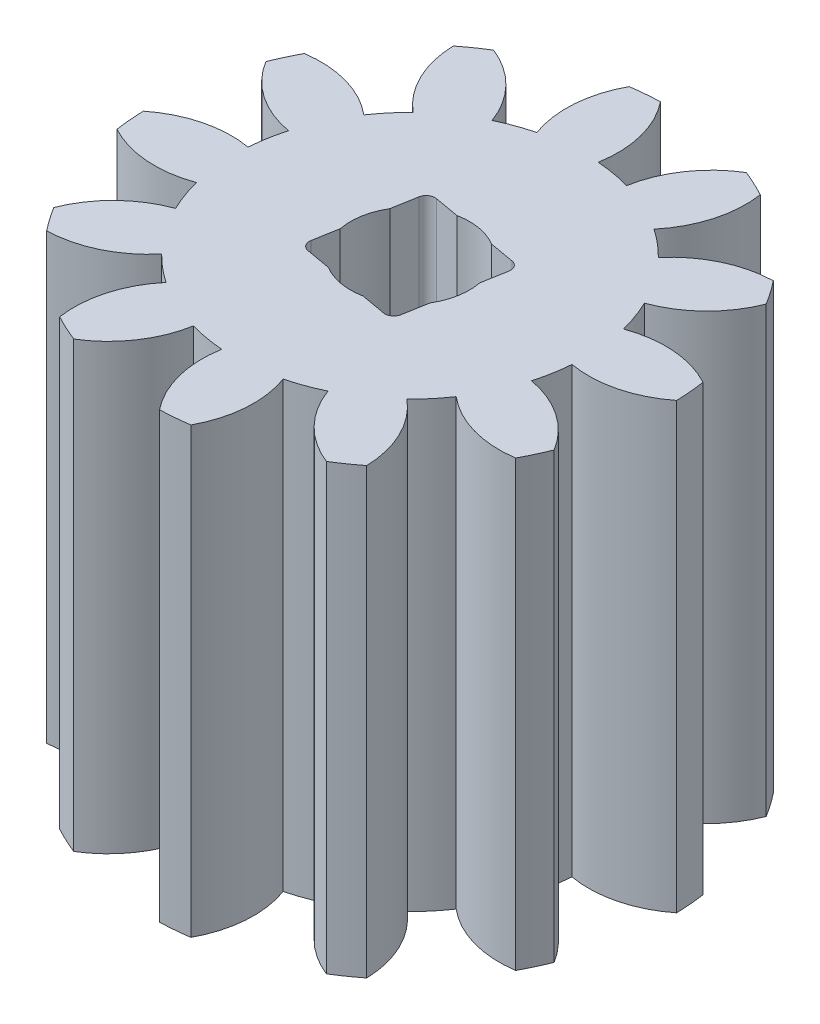
from build123d import *

# Parameters (mm, degrees)
BOSS_EXTRUDE1_DEPTH = 12.7
SKETCH2_R           = 1.7018
CUT_EXTRUDE1_DEPTH  = 56.896


with BuildPart() as part:
    # Sketch1 → Boss-Extrude1 (new body)
    with BuildSketch(Plane.XZ.offset(6.35)):
        with BuildLine():
            ThreePointArc((3.900741532, 6.293125734), (2.850773823, 5.595435975), (2.180140266, 4.527983952))
            ThreePointArc((2.180140266, 4.527983952), (1.71882223, 4.722425266), (1.240447645, 4.870004095))
            ThreePointArc((1.240447645, 4.870004095), (1.41285747, 6.118794727), (1.057001873, 7.328162323))
            ThreePointArc((1.057001873, 7.328162323), (0.645301119, 7.375825545), (0.231578393, 7.400377521))
            ThreePointArc((0.231578393, 7.400377521), (-0.328875436, 6.271176611), (-0.375935122, 5.011419263))
            ThreePointArc((-0.375935122, 5.011419263), (-0.872668917, 4.949151363), (-1.360742875, 4.837771086))
            ThreePointArc((-1.360742875, 4.837771086), (-1.835826903, 6.005460409), (-2.748690687, 6.874875672))
            ThreePointArc((-2.748690687, 6.874875672), (-3.12906561, 6.710302855), (-3.499635989, 6.524704127))
            ThreePointArc((-3.499635989, 6.524704127), (-3.420402788, 5.266560539), (-2.831278997, 4.15204883))
            ThreePointArc((-2.831278997, 4.15204883), (-3.230329132, 3.849756349), (-3.597323441, 3.509261221))
            ThreePointArc((-3.597323441, 3.509261221), (-4.592602939, 4.282967824), (-5.817873798, 4.579471636))
            ThreePointArc((-5.817873798, 4.579471636), (-6.065001736, 4.246759935), (-6.293125734, 3.900741532))
            ThreePointArc((-6.293125734, 3.900741532), (-5.595435975, 2.850773823), (-4.527983952, 2.180140266))
            ThreePointArc((-4.527983952, 2.180140266), (-4.722425266, 1.71882223), (-4.870004095, 1.240447645))
            ThreePointArc((-4.870004095, 1.240447645), (-6.118794727, 1.41285747), (-7.328162323, 1.057001873))
            ThreePointArc((-7.328162323, 1.057001873), (-7.375825545, 0.645301119), (-7.400377521, 0.231578393))
            ThreePointArc((-7.400377521, 0.231578393), (-6.271176611, -0.328875436), (-5.011419263, -0.375935122))
            ThreePointArc((-5.011419263, -0.375935122), (-4.949151363, -0.872668917), (-4.837771086, -1.360742875))
            ThreePointArc((-4.837771086, -1.360742875), (-6.005460409, -1.835826903), (-6.874875672, -2.748690687))
            ThreePointArc((-6.874875672, -2.748690687), (-6.710302855, -3.12906561), (-6.524704127, -3.499635989))
            ThreePointArc((-6.524704127, -3.499635989), (-5.266560539, -3.420402788), (-4.15204883, -2.831278997))
            ThreePointArc((-4.15204883, -2.831278997), (-3.849756349, -3.230329132), (-3.509261221, -3.597323441))
            ThreePointArc((-3.509261221, -3.597323441), (-4.282967824, -4.592602939), (-4.579471636, -5.817873798))
            ThreePointArc((-4.579471636, -5.817873798), (-4.246759935, -6.065001736), (-3.900741532, -6.293125734))
            ThreePointArc((-3.900741532, -6.293125734), (-2.850773823, -5.595435975), (-2.180140266, -4.527983952))
            ThreePointArc((-2.180140266, -4.527983952), (-1.71882223, -4.722425266), (-1.240447645, -4.870004095))
            ThreePointArc((-1.240447645, -4.870004095), (-1.41285747, -6.118794727), (-1.057001873, -7.328162323))
            ThreePointArc((-1.057001873, -7.328162323), (-0.645301119, -7.375825545), (-0.231578393, -7.400377521))
            ThreePointArc((-0.231578393, -7.400377521), (0.328875436, -6.271176611), (0.375935122, -5.011419263))
            ThreePointArc((0.375935122, -5.011419263), (0.872668917, -4.949151363), (1.360742875, -4.837771086))
            ThreePointArc((1.360742875, -4.837771086), (1.835826903, -6.005460409), (2.748690687, -6.874875672))
            ThreePointArc((2.748690687, -6.874875672), (3.12906561, -6.710302855), (3.499635989, -6.524704127))
            ThreePointArc((3.499635989, -6.524704127), (3.420402788, -5.266560539), (2.831278997, -4.15204883))
            ThreePointArc((2.831278997, -4.15204883), (3.230329132, -3.849756349), (3.597323441, -3.509261221))
            ThreePointArc((3.597323441, -3.509261221), (4.592602939, -4.282967824), (5.817873798, -4.579471636))
            ThreePointArc((5.817873798, -4.579471636), (6.065001736, -4.246759935), (6.293125734, -3.900741532))
            ThreePointArc((6.293125734, -3.900741532), (5.595435975, -2.850773823), (4.527983952, -2.180140266))
            ThreePointArc((4.527983952, -2.180140266), (4.722425266, -1.71882223), (4.870004095, -1.240447645))
            ThreePointArc((4.870004095, -1.240447645), (6.118794727, -1.41285747), (7.328162323, -1.057001873))
            ThreePointArc((7.328162323, -1.057001873), (7.375825545, -0.645301119), (7.400377521, -0.231578393))
            ThreePointArc((7.400377521, -0.231578393), (6.271176611, 0.328875436), (5.011419263, 0.375935122))
            ThreePointArc((5.011419263, 0.375935122), (4.949151363, 0.872668917), (4.837771086, 1.360742875))
            ThreePointArc((4.837771086, 1.360742875), (6.005460409, 1.835826903), (6.874875672, 2.748690687))
            ThreePointArc((6.874875672, 2.748690687), (6.710302855, 3.12906561), (6.524704127, 3.499635989))
            ThreePointArc((6.524704127, 3.499635989), (5.266560539, 3.420402788), (4.15204883, 2.831278997))
            ThreePointArc((4.15204883, 2.831278997), (3.849756349, 3.230329132), (3.509261221, 3.597323441))
            ThreePointArc((3.509261221, 3.597323441), (4.282967824, 4.592602939), (4.579471636, 5.817873798))
            ThreePointArc((4.579471636, 5.817873798), (4.246759935, 6.065001736), (3.900741532, 6.293125734))
        make_face()
        with BuildLine():
            Line((1.331822463, 1.588907621), (1.794942153, -1.037574657))
            ThreePointArc((1.794942153, -1.037574657), (1.752865603, -1.227369709), (1.588907621, -1.331822463))
            Line((1.588907621, -1.331822463), (-1.037574657, -1.794942153))
            ThreePointArc((-1.037574657, -1.794942153), (-1.227369709, -1.752865603), (-1.331822463, -1.588907621))
            Line((-1.331822463, -1.588907621), (-1.794942153, 1.037574657))
            ThreePointArc((-1.794942153, 1.037574657), (-1.752865603, 1.227369709), (-1.588907621, 1.331822463))
            Line((-1.588907621, 1.331822463), (1.037574657, 1.794942153))
            ThreePointArc((1.037574657, 1.794942153), (1.227369709, 1.752865603), (1.331822463, 1.588907621))
        make_face(mode=Mode.SUBTRACT)
    extrude(amount=-BOSS_EXTRUDE1_DEPTH)

    # Sketch2 → Cut-Extrude1 (cut)
    with BuildSketch(Plane(origin=(0, 6.35, 0), x_dir=(1, 0, 0), z_dir=(0, 1, 0))):
        Circle(SKETCH2_R)
    extrude(amount=-CUT_EXTRUDE1_DEPTH, mode=Mode.SUBTRACT)


solid = part.part
